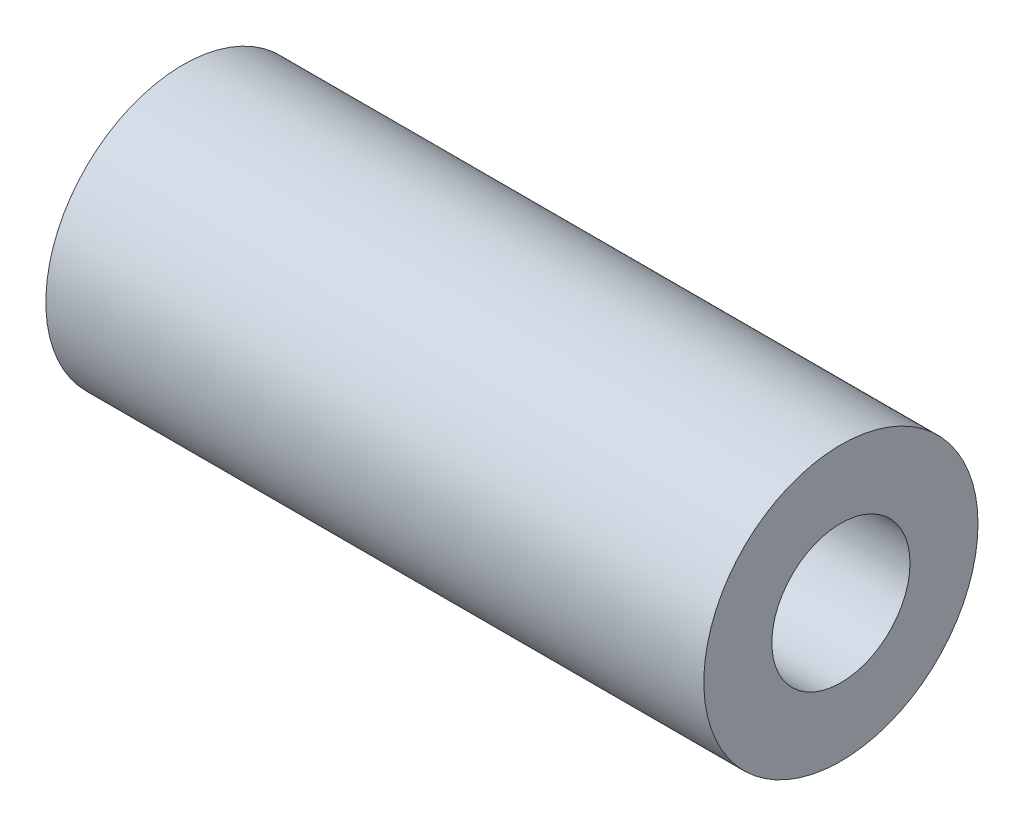
from build123d import *

# Parameters (mm, degrees)
SKETCH1_R           = 6.35
SKETCH1_R_2         = 3.2004
BOSS_EXTRUDE1_DEPTH = 30.48


with BuildPart() as part:
    # Sketch1 → Boss-Extrude1 (new body)
    with BuildSketch(Plane(origin=(0, 0, 0), x_dir=(0, 0, -1), z_dir=(1, 0, 0))):
        Circle(SKETCH1_R)
        Circle(SKETCH1_R_2, mode=Mode.SUBTRACT)
    extrude(amount=BOSS_EXTRUDE1_DEPTH)


solid = part.part
